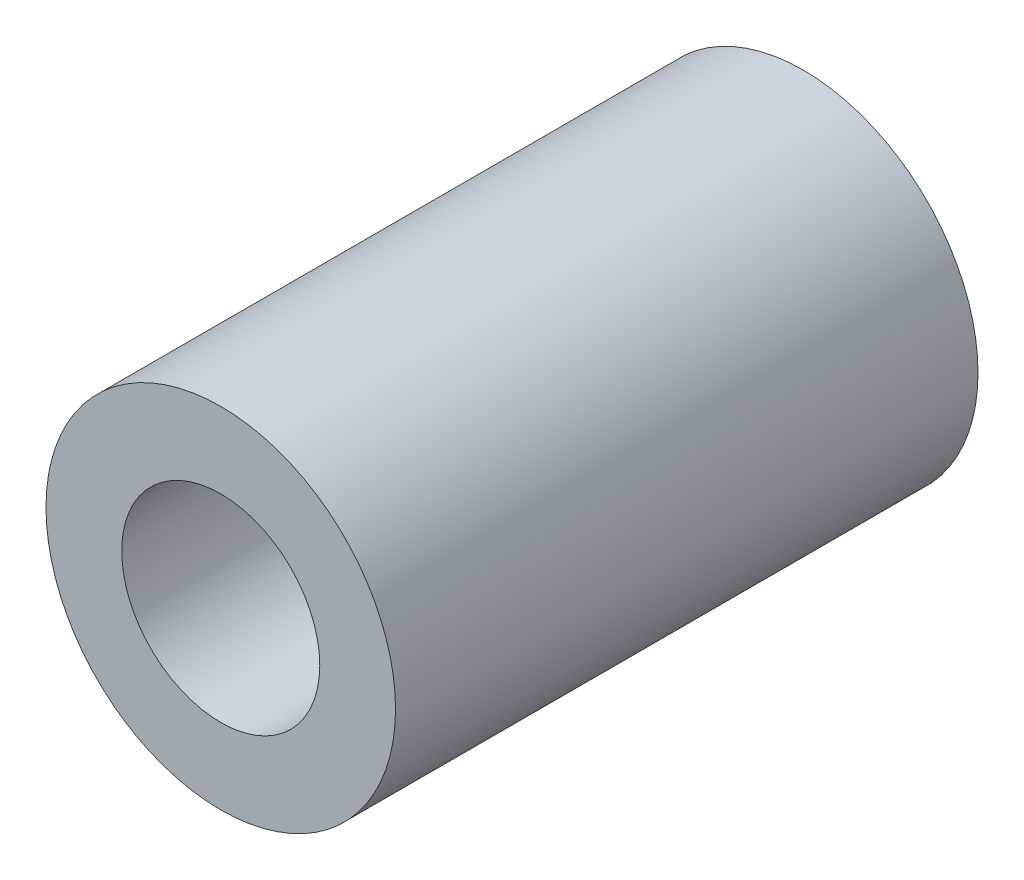
from build123d import *

# Parameters (mm, degrees)
SKETCH9_R           = 3
BOSS_EXTRUDE3_DEPTH = 10
SKETCH12_R          = 1.7
CUT_EXTRUDE2_DEPTH  = 11


with BuildPart() as part:
    # Sketch9 → Boss-Extrude3 (new body)
    with BuildSketch(Plane.XY):
        with Locations((-11.902732449, 30.059442964)):
            Circle(SKETCH9_R)
    extrude(amount=BOSS_EXTRUDE3_DEPTH)

    # Sketch12 → Cut-Extrude2 (cut, through all)
    with BuildSketch(Plane.XY.offset(10)):
        with Locations((-11.902732449, 30.059442964)):
            Circle(SKETCH12_R)
    extrude(amount=-CUT_EXTRUDE2_DEPTH, mode=Mode.SUBTRACT)


solid = part.part
